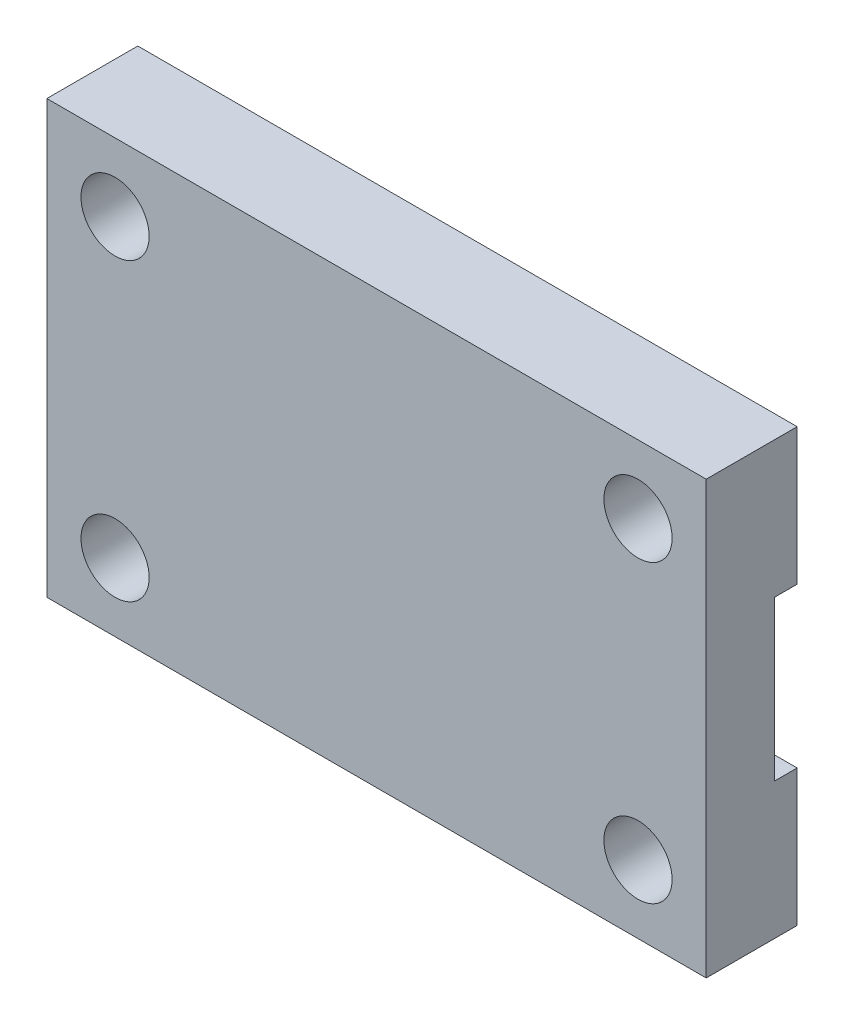
from build123d import *

# Parameters (mm, degrees)
SKETCH1_W           = 29
SKETCH1_H           = 19
SKETCH1_R           = 1.5
BOSS_EXTRUDE1_DEPTH = 4
SKETCH2_W           = 29
SKETCH2_H           = 7
CUT_EXTRUDE1_DEPTH  = 1


with BuildPart() as part:
    # Sketch1 → Boss-Extrude1 (new body)
    with BuildSketch(Plane.XY):
        with Locations((14.5, 9.5)):
            Rectangle(SKETCH1_W, SKETCH1_H)
        with Locations((3, 16)):
            Circle(SKETCH1_R, mode=Mode.SUBTRACT)
        with Locations((3, 3)):
            Circle(SKETCH1_R, mode=Mode.SUBTRACT)
        with Locations((26, 3)):
            Circle(SKETCH1_R, mode=Mode.SUBTRACT)
        with Locations((26, 16)):
            Circle(SKETCH1_R, mode=Mode.SUBTRACT)
    extrude(amount=BOSS_EXTRUDE1_DEPTH)

    # Sketch2 → Cut-Extrude1 (cut)
    with BuildSketch(Plane(origin=(0, 0, 0), x_dir=(-1, 0, 0), z_dir=(0, 0, -1))):
        with Locations((-14.5, 9.5)):
            Rectangle(SKETCH2_W, SKETCH2_H)
    extrude(amount=-CUT_EXTRUDE1_DEPTH, mode=Mode.SUBTRACT)


solid = part.part
